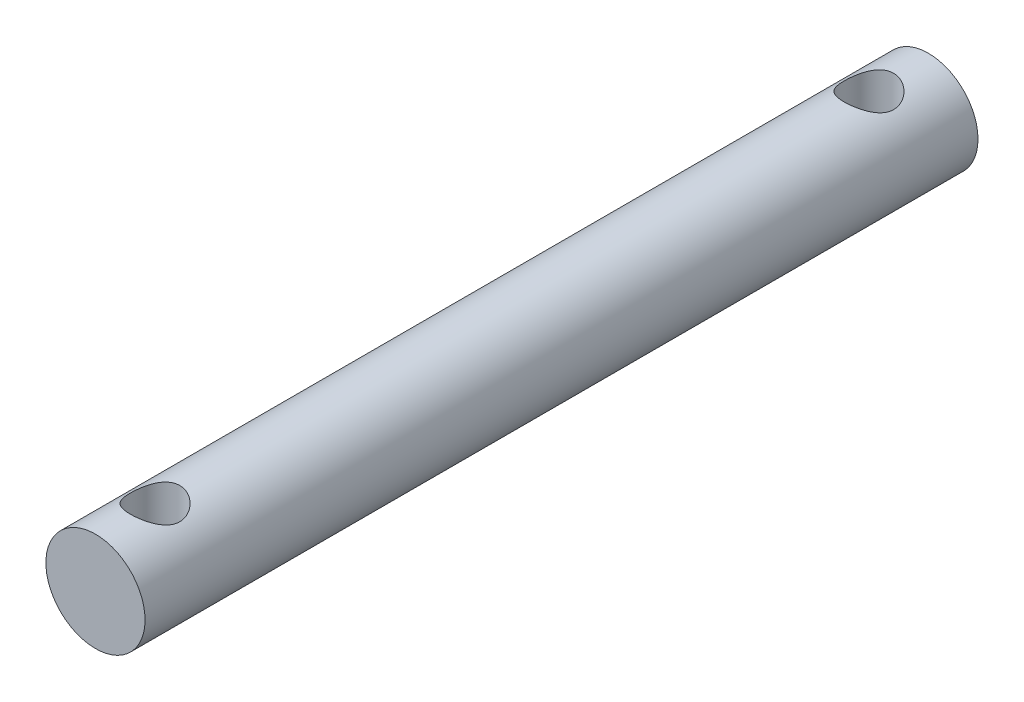
from build123d import *

# Parameters (mm, degrees)
SKETCH1_R               = 2.5
BOSS_EXTRUDE1_DEPTH     = 42
SKETCH2_R               = 1.25
CUT_EXTRUDE1_DEPTH      = 3.5
CUT_EXTRUDE1_DEPTH_BACK = 3.5


with BuildPart() as part:
    # Sketch1 → Boss-Extrude1 (new body)
    with BuildSketch(Plane.XY):
        Circle(SKETCH1_R)
    extrude(amount=BOSS_EXTRUDE1_DEPTH)

    # Sketch2 → Cut-Extrude1 (cut, two sides)
    with BuildSketch(Plane(origin=(0, 0, 0), x_dir=(1, 0, 0), z_dir=(0, 1, 0))) as cut_extrude1_sk:
        with Locations((0, -3)):
            Circle(SKETCH2_R)
        with Locations((0, -39)):
            Circle(SKETCH2_R)
    extrude(amount=CUT_EXTRUDE1_DEPTH, mode=Mode.SUBTRACT)
    extrude(cut_extrude1_sk.sketch, amount=-CUT_EXTRUDE1_DEPTH_BACK, mode=Mode.SUBTRACT)


solid = part.part
